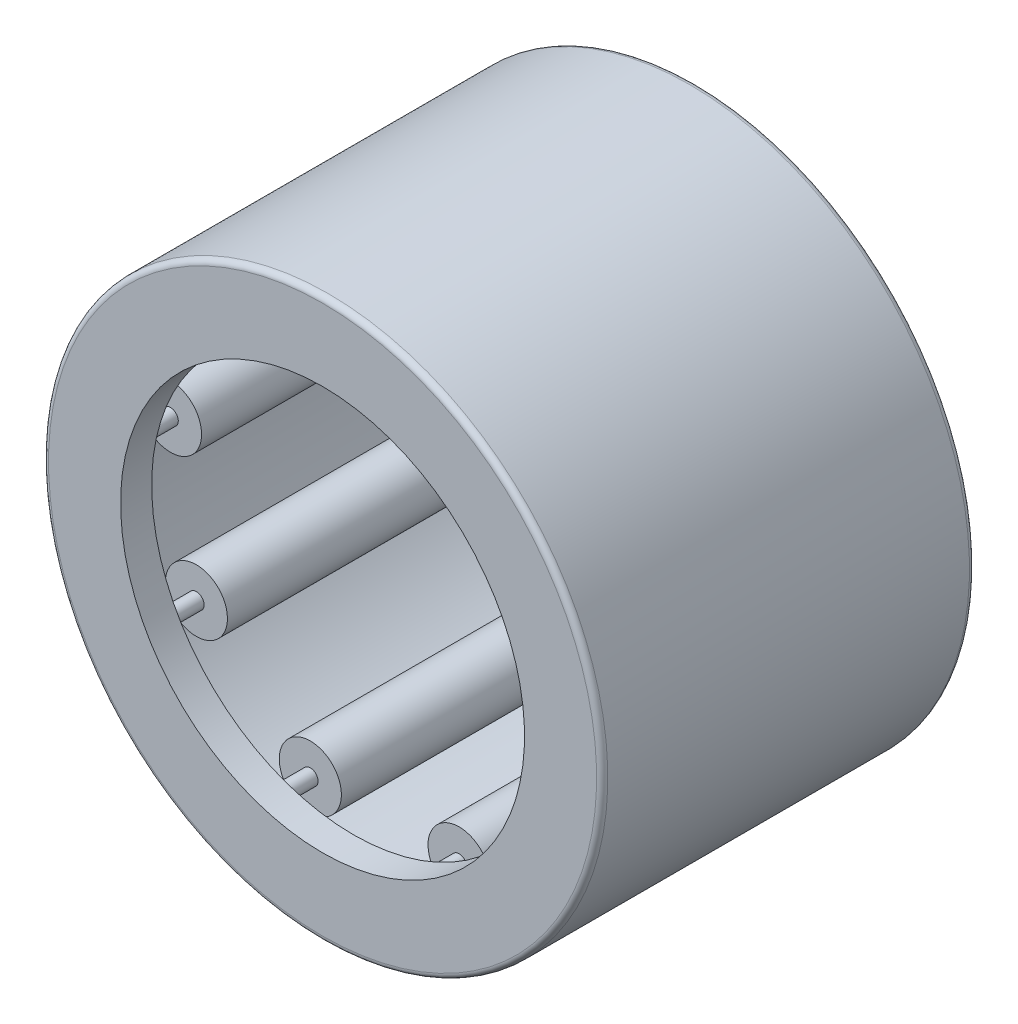
from build123d import *

# Parameters (mm, degrees)
SKETCH2_W         = 5.333333334
SKETCH2_H         = 0.5
SKETCH3_W         = 6.666666666
SKETCH3_H         = 0.166666666
CIRPATTERN1_COUNT = 9
CIRPATTERN1_ANGLE = 320
FILLET1_R         = 0.12


with BuildPart() as part:
    # Sketch1 → Revolve1 (revolve)
    with BuildSketch(Plane(origin=(0, 0, 0), x_dir=(0, 0, -1), z_dir=(1, 0, 0))):
        Polygon((-4, 6), (4, 6), (4, 4.333333333), (3.333333333, 4.333333333), (3.333333333, 5.333333333), (-3.333333333, 5.333333333), (-3.333333333, 4.333333333), (-4, 4.333333333), align=None)
    revolve(axis=Axis((0, 0, 4), (0, 0, -1)))

    # Fillet1
    fillet1_edges = [part.edges().sort_by_distance(p)[0] for p in [
        (0, -6, 4),
        (0, -6, -4),
    ]]
    fillet(fillet1_edges, radius=FILLET1_R)


with BuildPart() as body_2:
    # Sketch2 → Revolve2 (revolve)
    with BuildSketch(Plane(origin=(0, 0, 0), x_dir=(0, 0, -1), z_dir=(1, 0, 0))):
        with Locations((0, 5.083333333)):
            Rectangle(SKETCH2_W, SKETCH2_H)
    revolve(axis=Axis((0, 4.666666667, 2.666666667), (0, 0, -1)))


with BuildPart() as body_3:
    # Sketch3 → Revolve3 (revolve)
    with BuildSketch(Plane(origin=(0, 0, 0), x_dir=(0, 0, -1), z_dir=(1, 0, 0))):
        with Locations((0, 4.75)):
            Rectangle(SKETCH3_W, SKETCH3_H)
    revolve(axis=Axis((0, 4.666666667, 3.333333333), (0, 0, -1)))


with BuildPart() as cirpattern1_1:
    # CirPattern1: pattern copy
    add(body_2.part.rotate(Axis((0, 0, -4), (0, 0, 1)), 1 * CIRPATTERN1_ANGLE / (CIRPATTERN1_COUNT - 1)))


with BuildPart() as cirpattern1_2:
    # CirPattern1: pattern copy
    add(body_2.part.rotate(Axis((0, 0, -4), (0, 0, 1)), 2 * CIRPATTERN1_ANGLE / (CIRPATTERN1_COUNT - 1)))


with BuildPart() as cirpattern1_3:
    # CirPattern1: pattern copy
    add(body_2.part.rotate(Axis((0, 0, -4), (0, 0, 1)), 3 * CIRPATTERN1_ANGLE / (CIRPATTERN1_COUNT - 1)))


with BuildPart() as cirpattern1_4:
    # CirPattern1: pattern copy
    add(body_2.part.rotate(Axis((0, 0, -4), (0, 0, 1)), 4 * CIRPATTERN1_ANGLE / (CIRPATTERN1_COUNT - 1)))


with BuildPart() as cirpattern1_5:
    # CirPattern1: pattern copy
    add(body_2.part.rotate(Axis((0, 0, -4), (0, 0, 1)), 5 * CIRPATTERN1_ANGLE / (CIRPATTERN1_COUNT - 1)))


with BuildPart() as cirpattern1_6:
    # CirPattern1: pattern copy
    add(body_2.part.rotate(Axis((0, 0, -4), (0, 0, 1)), 6 * CIRPATTERN1_ANGLE / (CIRPATTERN1_COUNT - 1)))


with BuildPart() as cirpattern1_7:
    # CirPattern1: pattern copy
    add(body_2.part.rotate(Axis((0, 0, -4), (0, 0, 1)), 7 * CIRPATTERN1_ANGLE / (CIRPATTERN1_COUNT - 1)))


with BuildPart() as cirpattern1_8:
    # CirPattern1: pattern copy
    add(body_2.part.rotate(Axis((0, 0, -4), (0, 0, 1)), 8 * CIRPATTERN1_ANGLE / (CIRPATTERN1_COUNT - 1)))


with BuildPart() as cirpattern1_9:
    # CirPattern1: pattern copy
    add(body_3.part.rotate(Axis((0, 0, -4), (0, 0, 1)), 1 * CIRPATTERN1_ANGLE / (CIRPATTERN1_COUNT - 1)))


with BuildPart() as cirpattern1_10:
    # CirPattern1: pattern copy
    add(body_3.part.rotate(Axis((0, 0, -4), (0, 0, 1)), 2 * CIRPATTERN1_ANGLE / (CIRPATTERN1_COUNT - 1)))


with BuildPart() as cirpattern1_11:
    # CirPattern1: pattern copy
    add(body_3.part.rotate(Axis((0, 0, -4), (0, 0, 1)), 3 * CIRPATTERN1_ANGLE / (CIRPATTERN1_COUNT - 1)))


with BuildPart() as cirpattern1_12:
    # CirPattern1: pattern copy
    add(body_3.part.rotate(Axis((0, 0, -4), (0, 0, 1)), 4 * CIRPATTERN1_ANGLE / (CIRPATTERN1_COUNT - 1)))


with BuildPart() as cirpattern1_13:
    # CirPattern1: pattern copy
    add(body_3.part.rotate(Axis((0, 0, -4), (0, 0, 1)), 5 * CIRPATTERN1_ANGLE / (CIRPATTERN1_COUNT - 1)))


with BuildPart() as cirpattern1_14:
    # CirPattern1: pattern copy
    add(body_3.part.rotate(Axis((0, 0, -4), (0, 0, 1)), 6 * CIRPATTERN1_ANGLE / (CIRPATTERN1_COUNT - 1)))


with BuildPart() as cirpattern1_15:
    # CirPattern1: pattern copy
    add(body_3.part.rotate(Axis((0, 0, -4), (0, 0, 1)), 7 * CIRPATTERN1_ANGLE / (CIRPATTERN1_COUNT - 1)))


with BuildPart() as cirpattern1_16:
    # CirPattern1: pattern copy
    add(body_3.part.rotate(Axis((0, 0, -4), (0, 0, 1)), 8 * CIRPATTERN1_ANGLE / (CIRPATTERN1_COUNT - 1)))


solid = Compound([part.part, body_2.part, body_3.part, cirpattern1_1.part, cirpattern1_2.part, cirpattern1_3.part, cirpattern1_4.part, cirpattern1_5.part, cirpattern1_6.part, cirpattern1_7.part, cirpattern1_8.part, cirpattern1_9.part, cirpattern1_10.part, cirpattern1_11.part, cirpattern1_12.part, cirpattern1_13.part, cirpattern1_14.part, cirpattern1_15.part, cirpattern1_16.part])
